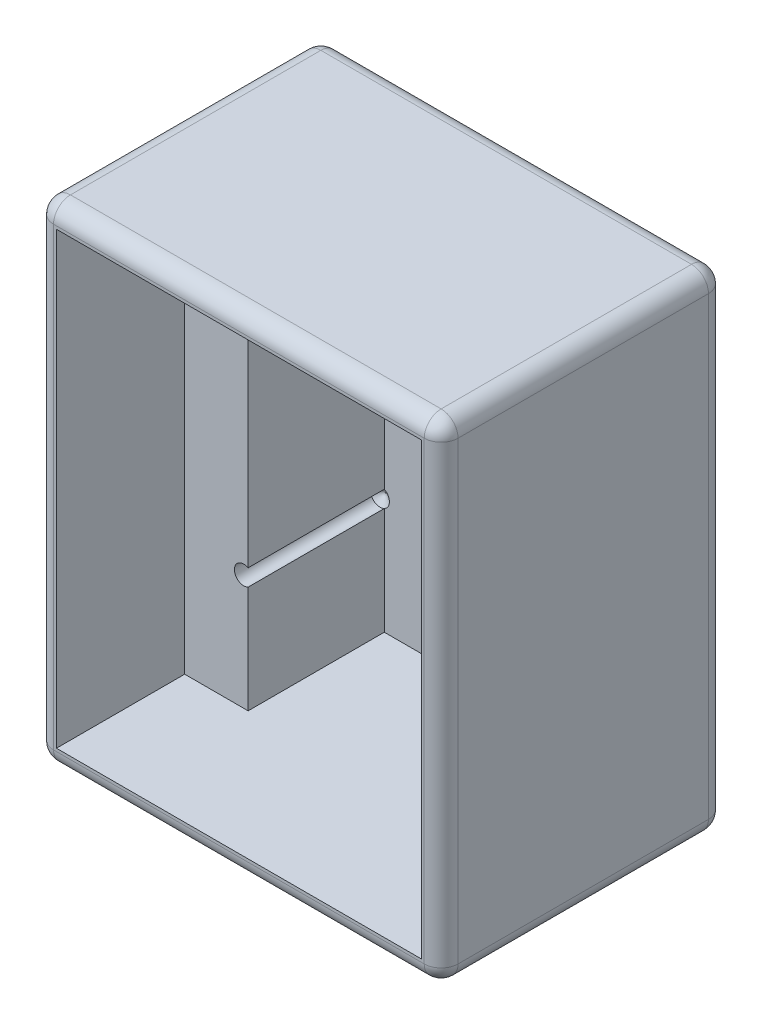
from build123d import *

# Parameters (mm, degrees)
SKETCH1_W                 = 48.5775
SKETCH1_H                 = 58.7375
BOSS_EXTRUDE1_DEPTH       = 34.13125
SKETCH2_W                 = 21.9075
SKETCH2_H                 = 53.975
CUT_EXTRUDE1_DEPTH        = 2.38125
SKETCH4_W                 = 14.2875
SKETCH4_H                 = 53.975
CUT_EXTRUDE2_DEPTH        = 29.36875
SKETCH5_W                 = 7.62
SKETCH5_H                 = 53.975
CUT_EXTRUDE3_DEPTH        = 13.0175
F_4_40_TAPPED_HOLE1_D     = 2.2606
F_4_40_TAPPED_HOLE1_DEPTH = 16.35125
F_4_40_TAPPED_HOLE1_TIP   = 0.679152758
FILLET3_R                 = 2.032
FILLET4_R                 = 2.032


with BuildPart() as part:
    # Sketch1 → Boss-Extrude1 (new body)
    with BuildSketch(Plane.XY):
        with Locations((0, -29.36875)):
            Rectangle(SKETCH1_W, SKETCH1_H)
    extrude(amount=BOSS_EXTRUDE1_DEPTH)

    # Sketch2 → Cut-Extrude1 (cut)
    with BuildSketch(Plane.XY.offset(34.13125)):
        with Locations((10.95375, -29.36875)):
            Rectangle(SKETCH2_W, SKETCH2_H)
        with Locations((-10.95375, -29.36875)):
            Rectangle(SKETCH2_W, SKETCH2_H)
    extrude(amount=-CUT_EXTRUDE1_DEPTH, mode=Mode.SUBTRACT)

    # Sketch4 → Cut-Extrude2 (cut)
    with BuildSketch(Plane.XY.offset(31.75)):
        with Locations((7.14375, -29.36875)):
            Rectangle(SKETCH4_W, SKETCH4_H)
        with Locations((-7.14375, -29.36875)):
            Rectangle(SKETCH4_W, SKETCH4_H)
    extrude(amount=-CUT_EXTRUDE2_DEPTH, mode=Mode.SUBTRACT)

    # Sketch5 → Cut-Extrude3 (cut)
    with BuildSketch(Plane.XY.offset(31.75)):
        with Locations((-18.0975, -29.36875)):
            Rectangle(SKETCH5_W, SKETCH5_H)
        with Locations((18.0975, -29.36875)):
            Rectangle(SKETCH5_W, SKETCH5_H)
    extrude(amount=-CUT_EXTRUDE3_DEPTH, mode=Mode.SUBTRACT)

    # #4-40 Tapped Hole1
    with Locations(Plane.XY.offset(18.7325)):
        with Locations((-14.8082, -16.2521392), (-14.8082, -42.4853608), (14.8082, -42.4853608), (14.8082, -16.2521392)):
            Hole(F_4_40_TAPPED_HOLE1_D / 2, depth=F_4_40_TAPPED_HOLE1_DEPTH)
            with Locations((0, 0, -(F_4_40_TAPPED_HOLE1_DEPTH + F_4_40_TAPPED_HOLE1_TIP / 2))):  # 118° drill point
                Cone(0, F_4_40_TAPPED_HOLE1_D / 2, F_4_40_TAPPED_HOLE1_TIP, mode=Mode.SUBTRACT)

    # Fillet3
    fillet3_edges = [part.edges().sort_by_distance(p)[0] for p in [
        (-24.28875, -29.36875, 34.13125),
    ]]
    fillet(fillet3_edges, radius=FILLET3_R)

    # Fillet4
    fillet4_edges = [part.edges().sort_by_distance(p)[0] for p in [
        (-24.28875, -58.7375, 16.049625),
        (-23.693590979, -58.7375, 33.536090979),
        (-24.28875, 0, 16.049625),
        (-23.693590979, 0, 33.536090979),
        (1.016, 0, 34.13125),
        (24.28875, -29.36875, 34.13125),
        (0, 0, 0),
        (-24.28875, -29.36875, 0),
        (0, -58.7375, 0),
        (24.28875, -29.36875, 0),
        (1.016, -58.7375, 34.13125),
        (24.28875, 0, 17.065625),
        (24.28875, -58.7375, 17.065625),
    ]]
    fillet(fillet4_edges, radius=FILLET4_R)


solid = part.part
